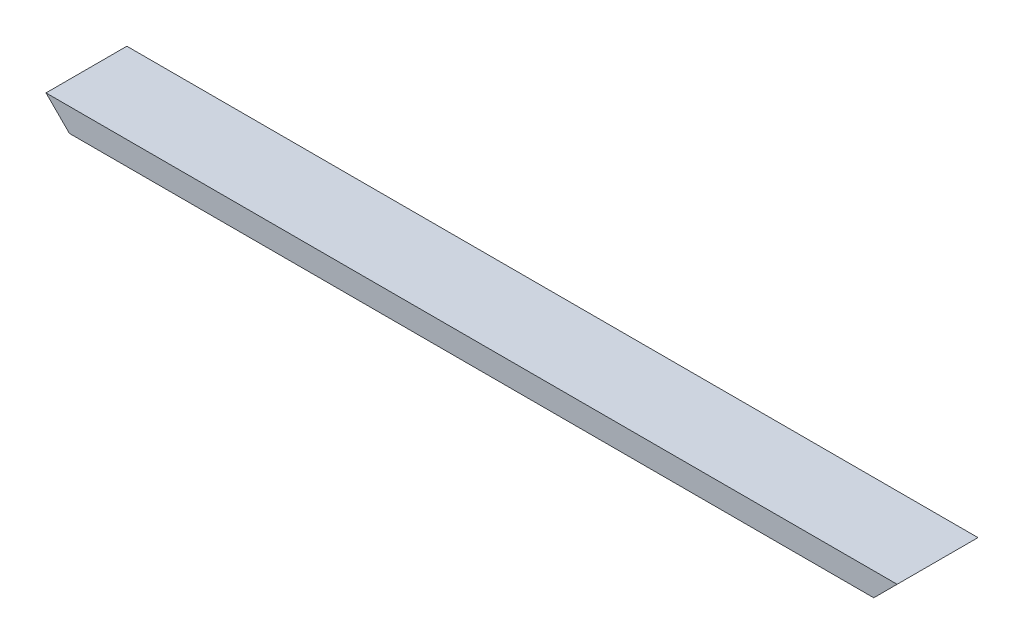
from build123d import *

# Parameters (mm, degrees)
SKETCH1_W               = 38
SKETCH1_H               = 11
SKETCH1_W_2             = 35
SKETCH1_H_2             = 8
BOSS_EXTRUDE1_DEPTH     = 400
CUT_EXTRUDE1_DEPTH      = 1
CUT_EXTRUDE1_DEPTH_BACK = 39
CUT_EXTRUDE3_DEPTH      = 1
CUT_EXTRUDE3_DEPTH_BACK = 39


with BuildPart() as part:
    # Sketch1 → Boss-Extrude1 (new body)
    with BuildSketch(Plane(origin=(0, 0, 0), x_dir=(0, 0, -1), z_dir=(1, 0, 0))):
        Rectangle(SKETCH1_W, SKETCH1_H)
        Rectangle(SKETCH1_W_2, SKETCH1_H_2, mode=Mode.SUBTRACT)
    extrude(amount=BOSS_EXTRUDE1_DEPTH)

    # Sketch2 → Cut-Extrude1 (cut, two sides)
    with BuildSketch(Plane(origin=(0, 0, -19), x_dir=(-1, 0, 0), z_dir=(0, 0, -1))) as cut_extrude1_sk:
        Polygon((572.970352137, 578.470352137), (0, 5.5), (-11, -5.5), (-583.970352137, -578.470352137), (561.970352137, -1724.411056412), (1718.911056412, -567.470352137), align=None)
    extrude(amount=CUT_EXTRUDE1_DEPTH, mode=Mode.SUBTRACT)
    extrude(cut_extrude1_sk.sketch, amount=-CUT_EXTRUDE1_DEPTH_BACK, mode=Mode.SUBTRACT)

    # Sketch3 → Cut-Extrude3 (cut, two sides)
    with BuildSketch(Plane(origin=(0, 0, -19), x_dir=(-1, 0, 0), z_dir=(0, 0, -1))) as cut_extrude3_sk:
        Polygon((-972.970352137, 578.470352137), (-400, 5.5), (-389, -5.5), (183.970352137, -578.470352137), (-961.970352137, -1724.411056412), (-2118.911056412, -567.470352137), align=None)
    extrude(amount=CUT_EXTRUDE3_DEPTH, mode=Mode.SUBTRACT)
    extrude(cut_extrude3_sk.sketch, amount=-CUT_EXTRUDE3_DEPTH_BACK, mode=Mode.SUBTRACT)


solid = part.part
